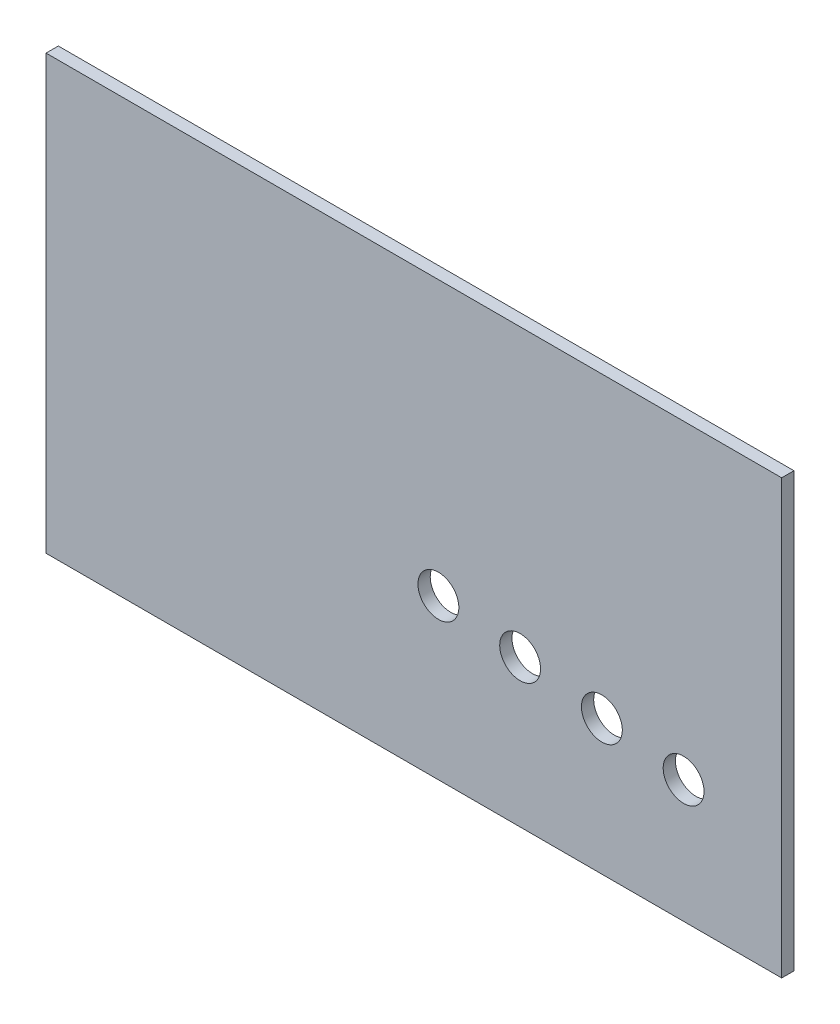
from build123d import *

# Parameters (mm, degrees)
SKETCH1_W           = 900
SKETCH1_H           = 530
BOSS_EXTRUDE1_DEPTH = 15
SKETCH3_R           = 25
CUT_EXTRUDE1_DEPTH  = 16


with BuildPart() as part:
    # Sketch1 → Boss-Extrude1 (new body)
    with BuildSketch(Plane.XY):
        with Locations((450, 265)):
            Rectangle(SKETCH1_W, SKETCH1_H)
    extrude(amount=BOSS_EXTRUDE1_DEPTH)

    # Sketch3 → Cut-Extrude1 (cut, through all)
    with BuildSketch(Plane(origin=(0, 0, 0), x_dir=(-1, 0, 0), z_dir=(0, 0, -1))):
        with Locations((-780, 150)):
            Circle(SKETCH3_R)
        with Locations((-680, 165)):
            Circle(SKETCH3_R)
        with Locations((-580, 180)):
            Circle(SKETCH3_R)
        with Locations((-480, 195)):
            Circle(SKETCH3_R)
    extrude(amount=-CUT_EXTRUDE1_DEPTH, mode=Mode.SUBTRACT)


solid = part.part
